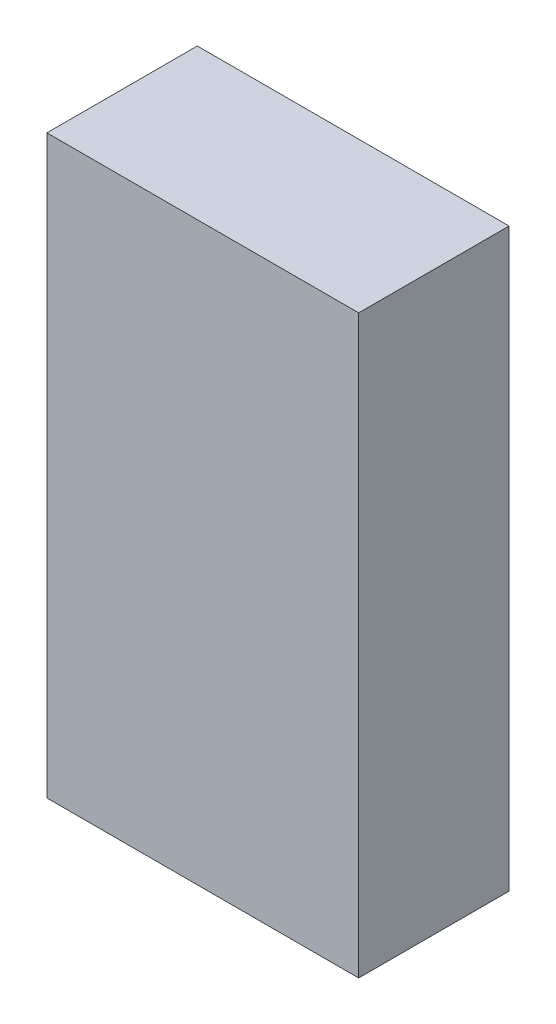
from build123d import *

# Parameters (mm, degrees)
SKETCH1_W           = 20.725368984
SKETCH1_H           = 38.292622135
BOSS_EXTRUDE1_DEPTH = 10


with BuildPart() as part:
    # Sketch1 → Boss-Extrude1 (new body)
    with BuildSketch(Plane.XY):
        with Locations((10.362684492, 19.146311068)):
            Rectangle(SKETCH1_W, SKETCH1_H)
    extrude(amount=BOSS_EXTRUDE1_DEPTH)


solid = part.part
